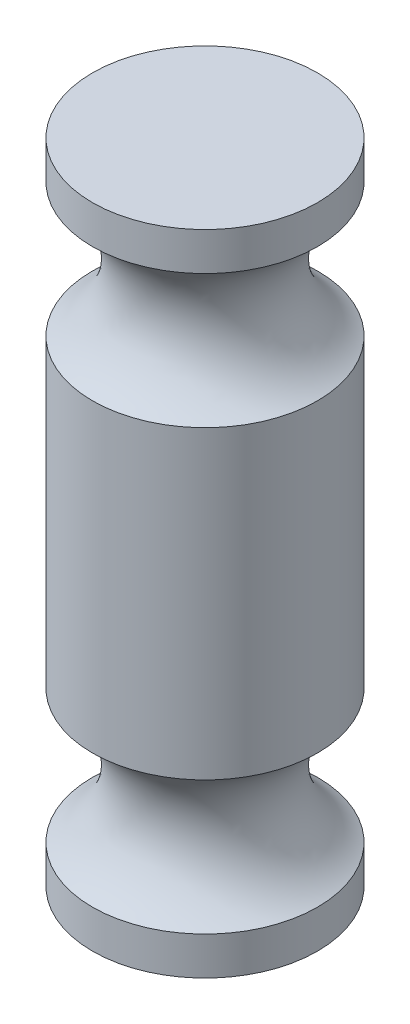
from build123d import *


with BuildPart() as part:
    # 草图1 → 旋转1 (revolve)
    with BuildSketch(Plane.XY):
        with BuildLine():
            Line((0, 0), (0, 8.56))
            Line((0, 8.56), (2.95, 8.56))
            Line((2.95, 8.56), (2.95, 7.56))
            ThreePointArc((2.95, 7.56), (1.918245837, 5.81), (2.95, 4.06))
            Line((2.95, 4.06), (2.95, -3.94))
            ThreePointArc((2.95, -3.94), (1.918245837, -5.69), (2.95, -7.44))
            Line((2.95, -7.44), (2.95, -8.44))
            Line((2.95, -8.44), (0, -8.44))
            Line((0, -8.44), (0, 0))
        make_face()
    revolve(axis=Axis((0, -8.44, 0), (0, 1, 0)))


solid = part.part
